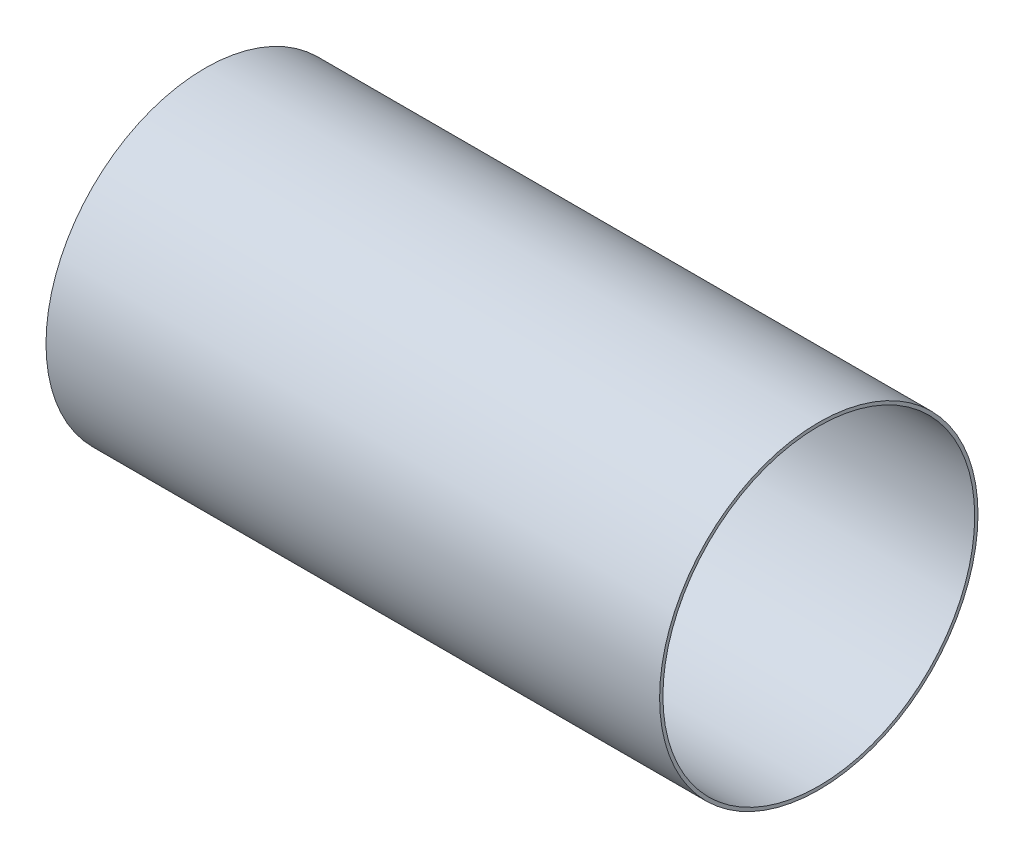
from build123d import *

# Parameters (mm, degrees)
SKETCH1_W = 37
SKETCH1_H = 0.2


with BuildPart() as part:
    # Sketch1 → Revolve1 (revolve)
    with BuildSketch(Plane.XY):
        with Locations((18.5, 9.5)):
            Rectangle(SKETCH1_W, SKETCH1_H)
    revolve(axis=Axis((88.99, 0, 0), (-1, 0, 0)))


solid = part.part
